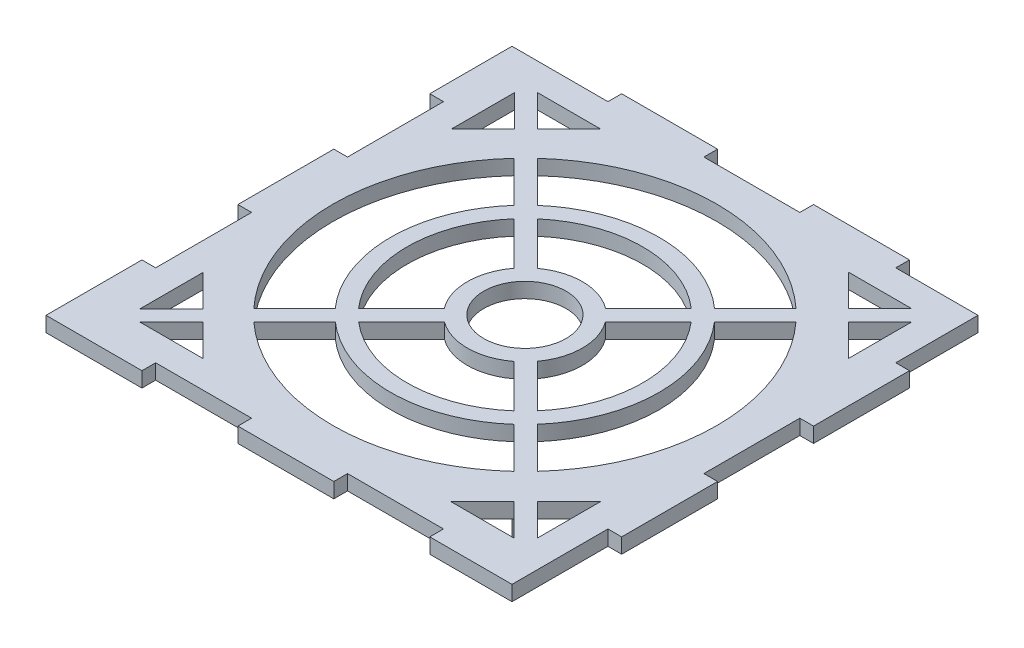
from build123d import *

# Parameters (mm, degrees)
SKETCH_1_R      = 15
EXTRUDE_2_DEPTH = 5.5
EXTRUDE_3_DEPTH = 23


with BuildPart() as part:
    # Эскиз1 → Бобышка-Вытянуть2 (new body)
    with BuildSketch(Plane(origin=(0, 0, 0), x_dir=(1, 0, 0), z_dir=(0, 1, 0))):
        Polygon((170, 140), (170, 170), (140, 170), (140, 175), (105, 175), (105, 170), (70, 170), (70, 175), (35, 175), (35, 170), (0, 170), (0, 140), (5, 140), (5, 105), (0, 105), (0, 70), (5, 70), (5, 35), (0, 35), (0, 0), (35, 0), (35, 5), (70, 5), (70, 0), (105, 0), (105, 5), (140, 5), (140, 0), (170, 0), (170, 35), (175, 35), (175, 70), (170, 70), (170, 105), (175, 105), (175, 140), align=None)
        Polygon((19.339817755, 14.98716546), (30.853332638, 26.500680342), (42.36684752, 14.98716546), align=None, mode=Mode.SUBTRACT)
        Polygon((26.610691951, 30.743321029), (15.097177068, 19.229806147), (15.097177068, 42.256835911), align=None, mode=Mode.SUBTRACT)
        with BuildLine():
            ThreePointArc((54.899758827, 50.65711814), (87.41386875, 38.50044692), (119.822950774, 50.934408539))
            Line((119.822950774, 50.934408539), (134.689086203, 36.06827311))
            ThreePointArc((134.689086203, 36.06827311), (87.41366824, 17.500312244), (40.028175023, 35.785534336))
            Line((40.028175023, 35.785534336), (54.899758827, 50.65711814))
        make_face(mode=Mode.SUBTRACT)
        with BuildLine():
            Line((35.772862168, 134.984497145), (50.638997596, 120.118361717))
            ThreePointArc((50.638997596, 120.118361717), (38.204589058, 87.5), (50.638997596, 54.881638283))
            Line((50.638997596, 54.881638283), (35.772862168, 40.015502855))
            ThreePointArc((35.772862168, 40.015502855), (17.204589058, 87.5), (35.772862168, 134.984497145))
        make_face(mode=Mode.SUBTRACT)
        with BuildLine():
            ThreePointArc((74.798754674, 70.556113987), (87.415641051, 66.501060573), (99.948475479, 70.808883834))
            Line((99.948475479, 70.808883834), (115.572444887, 55.184914426))
            ThreePointArc((115.572444887, 55.184914426), (87.413986392, 44.500509855), (59.152804826, 54.910164139))
            Line((59.152804826, 54.910164139), (74.798754674, 70.556113987))
        make_face(mode=Mode.SUBTRACT)
        Polygon((155.770193853, 14.98716546), (132.743164089, 14.98716546), (144.256678971, 26.500680342), align=None, mode=Mode.SUBTRACT)
        Polygon((160.01283454, 19.229806147), (148.499319658, 30.743321029), (160.01283454, 42.256835911), align=None, mode=Mode.SUBTRACT)
        with BuildLine():
            Line((54.889503484, 115.867855829), (70.513472891, 100.243886422))
            ThreePointArc((70.513472891, 100.243886422), (66.204589058, 87.5), (70.513472891, 74.756113578))
            Line((70.513472891, 74.756113578), (54.889503484, 59.132144171))
            ThreePointArc((54.889503484, 59.132144171), (44.204589058, 87.5), (54.889503484, 115.867855829))
        make_face(mode=Mode.SUBTRACT)
        with BuildLine():
            Line((115.572444887, 119.815085574), (99.948475479, 104.191116166))
            ThreePointArc((99.948475479, 104.191116166), (87.415641051, 108.498939427), (74.798754674, 104.443886013))
            Line((74.798754674, 104.443886013), (59.152804826, 120.089835861))
            ThreePointArc((59.152804826, 120.089835861), (87.413986392, 130.499490145), (115.572444887, 119.815085574))
        make_face(mode=Mode.SUBTRACT)
        Polygon((15.097177068, 132.743164089), (15.097177068, 155.770193853), (26.610691951, 144.256678971), align=None, mode=Mode.SUBTRACT)
        Polygon((19.339817755, 160.01283454), (42.36684752, 160.01283454), (30.853332638, 148.499319658), align=None, mode=Mode.SUBTRACT)
        with BuildLine():
            Line((134.689086203, 138.93172689), (119.822950774, 124.065591461))
            ThreePointArc((119.822950774, 124.065591461), (87.41386875, 136.49955308), (54.899758827, 124.34288186))
            Line((54.899758827, 124.34288186), (40.028175023, 139.214465664))
            ThreePointArc((40.028175023, 139.214465664), (87.41366824, 157.499687756), (134.689086203, 138.93172689))
        make_face(mode=Mode.SUBTRACT)
        with Locations((87.204589058, 87.5)):
            Circle(SKETCH_1_R, mode=Mode.SUBTRACT)
        with BuildLine():
            ThreePointArc((104.148475071, 75.094165616), (108.204589058, 87.5), (104.148475071, 99.905834384))
            Line((104.148475071, 99.905834384), (119.794424918, 115.551784231))
            ThreePointArc((119.794424918, 115.551784231), (130.204589058, 87.5), (119.794424918, 59.448215769))
            Line((119.794424918, 59.448215769), (104.148475071, 75.094165616))
        make_face(mode=Mode.SUBTRACT)
        with BuildLine():
            ThreePointArc((124.047470918, 55.195169769), (136.204589058, 87.5), (124.047470918, 119.804830231))
            Line((124.047470918, 119.804830231), (138.919054721, 134.676414034))
            ThreePointArc((138.919054721, 134.676414034), (157.204589058, 87.5), (138.919054721, 40.323585966))
            Line((138.919054721, 40.323585966), (124.047470918, 55.195169769))
        make_face(mode=Mode.SUBTRACT)
        Polygon((160.01283454, 132.743164089), (148.499319658, 144.256678971), (160.01283454, 155.770193853), align=None, mode=Mode.SUBTRACT)
        Polygon((132.743164089, 160.01283454), (155.770193853, 160.01283454), (144.256678971, 148.499319658), align=None, mode=Mode.SUBTRACT)
    extrude(amount=EXTRUDE_2_DEPTH)

    # Эскиз2 → Бобышка-Вытянуть3 (add)
    with BuildSketch(Plane(origin=(0, 5.5, 0), x_dir=(1, 0, 0), z_dir=(0, 1, 0))):
        Polygon((30.853332638, 148.499319658), (26.610691951, 144.256678971), (31.568480277, 139.298890644), (35.811120964, 143.541531331), align=None)
        Polygon((148.203908716, 143.85125642), (143.961268028, 148.093897107), (139.003479702, 143.136108781), (143.246120389, 138.893468093), align=None)
        Polygon((143.555845478, 26.500680342), (147.798486165, 30.743321029), (142.840697838, 35.701109356), (138.598057151, 31.458468669), align=None)
        Polygon((26.2052694, 31.14874358), (30.447910087, 26.906102893), (35.405698413, 31.863891219), (31.163057726, 36.106531907), align=None)
    extrude(amount=-EXTRUDE_3_DEPTH)


solid = part.part
